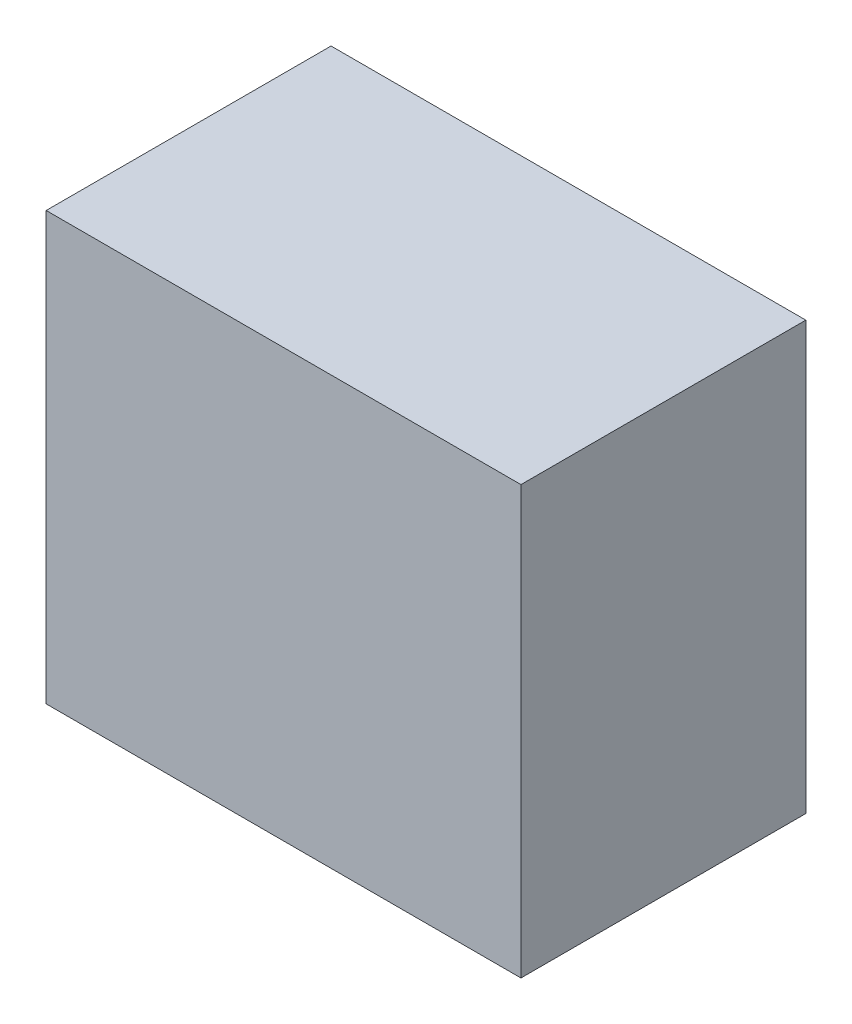
from build123d import *

# Parameters (mm, degrees)
SKETCH1_W           = 1016
SKETCH1_H           = 914.4
BOSS_EXTRUDE1_DEPTH = 609.6


with BuildPart() as part:
    # Sketch1 → Boss-Extrude1 (new body)
    with BuildSketch(Plane.XY):
        Rectangle(SKETCH1_W, SKETCH1_H)
    extrude(amount=BOSS_EXTRUDE1_DEPTH)


solid = part.part
